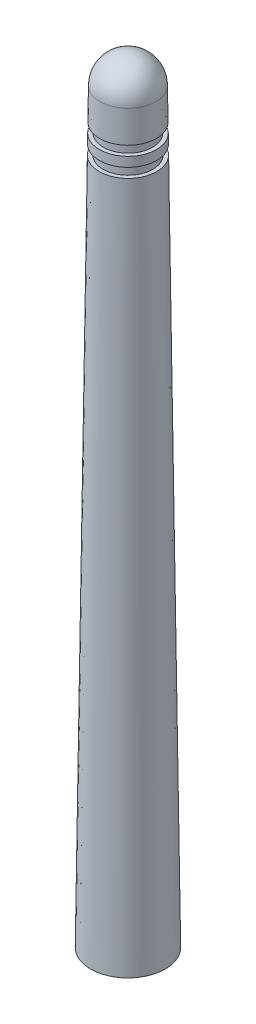
from build123d import *


with BuildPart() as part:
    # Croquis1 → Revolución1 (revolve)
    with BuildSketch(Plane.XY):
        with BuildLine():
            Line((0, 0), (-5, 0))
            Line((-5, 0), (-3.850771176, 91.938305952))
            Line((-3.850771176, 91.938305952), (-3.334888704, 91.938305952))
            Line((-3.334888704, 91.938305952), (-3.334888704, 93.208903719))
            Line((-3.334888704, 93.208903719), (-3.834888704, 93.208903719))
            Line((-3.834888704, 93.208903719), (-3.819007472, 94.479402233))
            Line((-3.819007472, 94.479402233), (-3.303125, 94.479402233))
            Line((-3.303125, 94.479402233), (-3.303125, 95.75))
            Line((-3.303125, 95.75), (-3.803125, 95.75))
            Line((-3.803125, 95.75), (-3.75, 100))
            ThreePointArc((-3.75, 100), (-2.651650429, 102.651650429), (0, 103.75))
            Line((0, 103.75), (0, 100))
            Line((0, 100), (0, 0))
        make_face()
    revolve(axis=Axis((0, 100, 0), (0, -1, 0)))


solid = part.part
